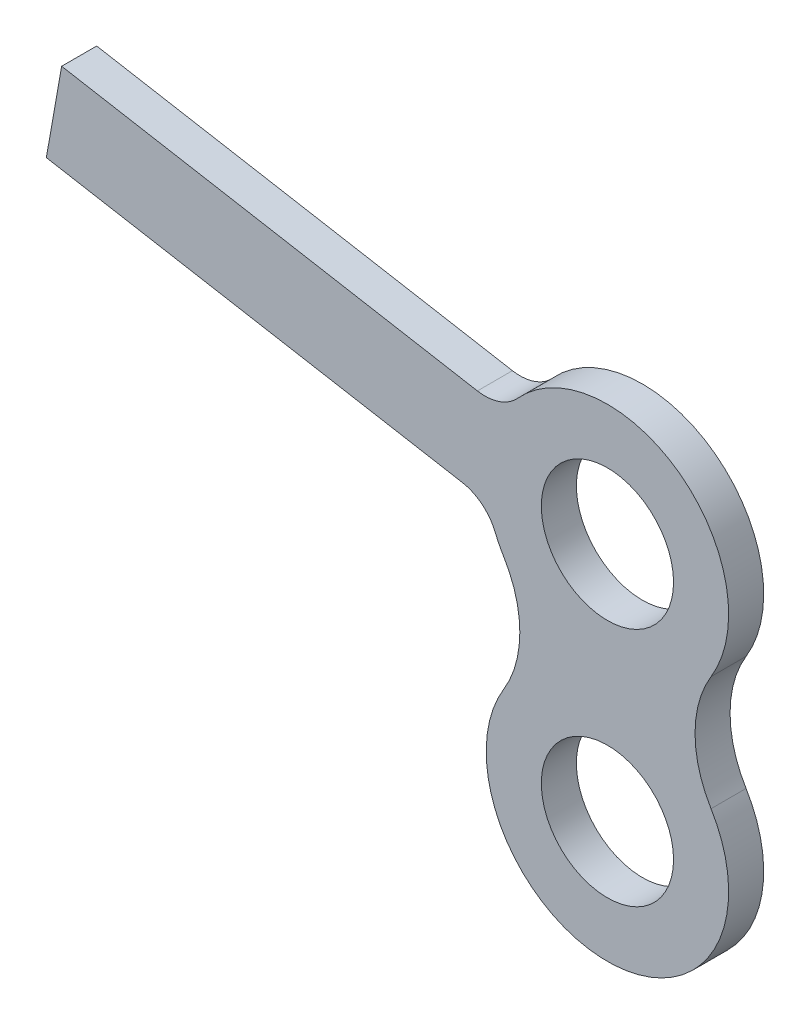
from build123d import *

# Parameters (mm, degrees)
SKETCH1_R           = 3
BOSS_EXTRUDE1_DEPTH = 1.59


with BuildPart() as part:
    # Sketch1 → Boss-Extrude1 (new body)
    with BuildSketch(Plane.XY):
        with BuildLine():
            ThreePointArc((-5.900608413, 13.97128969), (-4.905988344, 14.048559559), (-4.072428842, 14.59666381))
            ThreePointArc((-4.072428842, 14.59666381), (3.290759997, 15.306914867), (4.701099283, 8.045238095))
            ThreePointArc((4.701099283, 8.045238095), (3.974825904, 5.45), (4.701099283, 2.854761905))
            ThreePointArc((4.701099283, 2.854761905), (0, -5.5), (-4.701099283, 2.854761905))
            ThreePointArc((-4.701099283, 2.854761905), (-3.974825904, 5.45), (-4.701099283, 8.045238095))
            ThreePointArc((-4.701099283, 8.045238095), (-4.911398404, 8.424486778), (-5.091164818, 8.819124992))
            ThreePointArc((-5.091164818, 8.819124992), (-5.686991836, 9.619268653), (-6.595201124, 10.032058678))
            Line((-6.595201124, 10.032058678), (-25.459894057, 13.358413024))
            Line((-25.459894057, 13.358413024), (-24.765301346, 17.297644037))
            Line((-24.765301346, 17.297644037), (-5.900608413, 13.97128969))
        make_face()
        Circle(SKETCH1_R, mode=Mode.SUBTRACT)
        with Locations((0, 10.9)):
            Circle(SKETCH1_R, mode=Mode.SUBTRACT)
    extrude(amount=BOSS_EXTRUDE1_DEPTH)


solid = part.part
